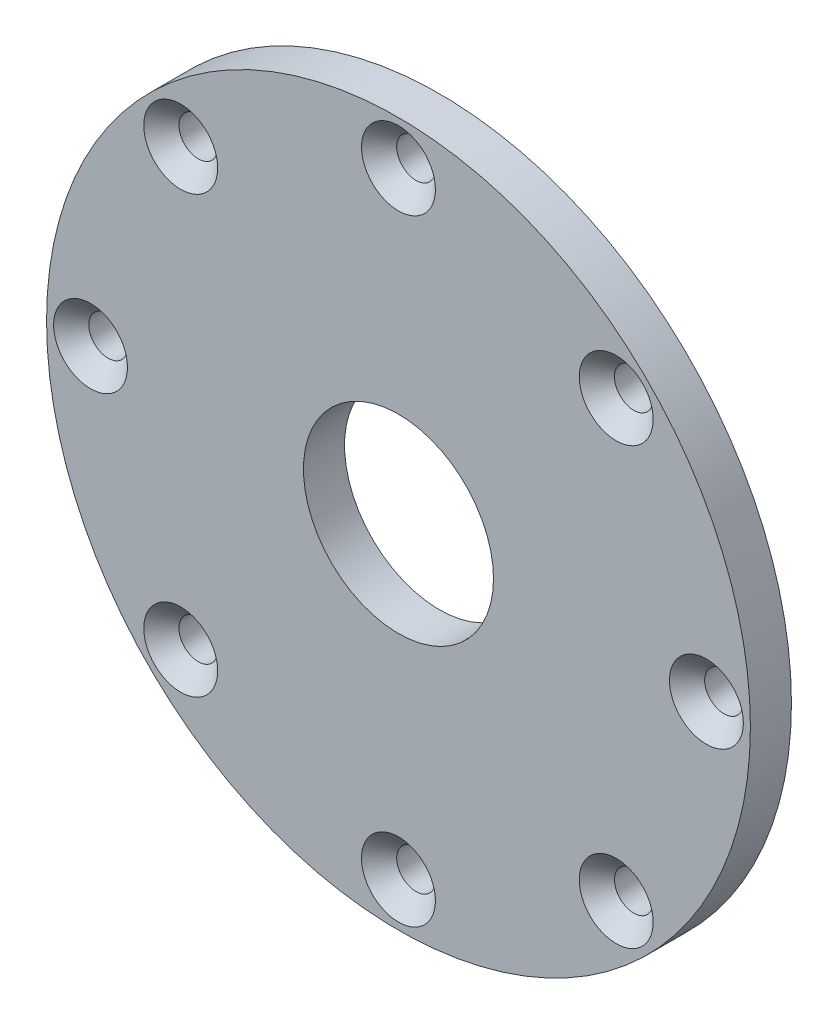
from build123d import *

# Parameters (mm, degrees)
SKETCH1_R                                           = 60
SKETCH1_R_2                                         = 16.2
BOSS_EXTRUDE1_DEPTH                                 = 7
CSK_FOR_M6_COUNTERSUNK_FLAT_HEAD_SCREW1_D           = 6.6
CSK_FOR_M6_COUNTERSUNK_FLAT_HEAD_SCREW1_CSINK_D     = 12.6
CSK_FOR_M6_COUNTERSUNK_FLAT_HEAD_SCREW1_CSINK_ANGLE = 90


with BuildPart() as part:
    # Sketch1 → Boss-Extrude1 (new body)
    with BuildSketch(Plane.XY):
        Circle(SKETCH1_R)
        Circle(SKETCH1_R_2, mode=Mode.SUBTRACT)
    extrude(amount=BOSS_EXTRUDE1_DEPTH)

    # CSK for M6 Countersunk Flat Head Screw1 (through all)
    with Locations(Plane.XY.offset(7)):
        with Locations((-37.123106012, 37.123106012), (0, 52.5), (37.123106012, 37.123106012), (52.5, 0), (37.123106012, -37.123106012), (0, -52.5), (-37.123106012, -37.123106012), (-52.5, 0)):
            CounterSinkHole(CSK_FOR_M6_COUNTERSUNK_FLAT_HEAD_SCREW1_D / 2, CSK_FOR_M6_COUNTERSUNK_FLAT_HEAD_SCREW1_CSINK_D / 2, counter_sink_angle=CSK_FOR_M6_COUNTERSUNK_FLAT_HEAD_SCREW1_CSINK_ANGLE)


solid = part.part
